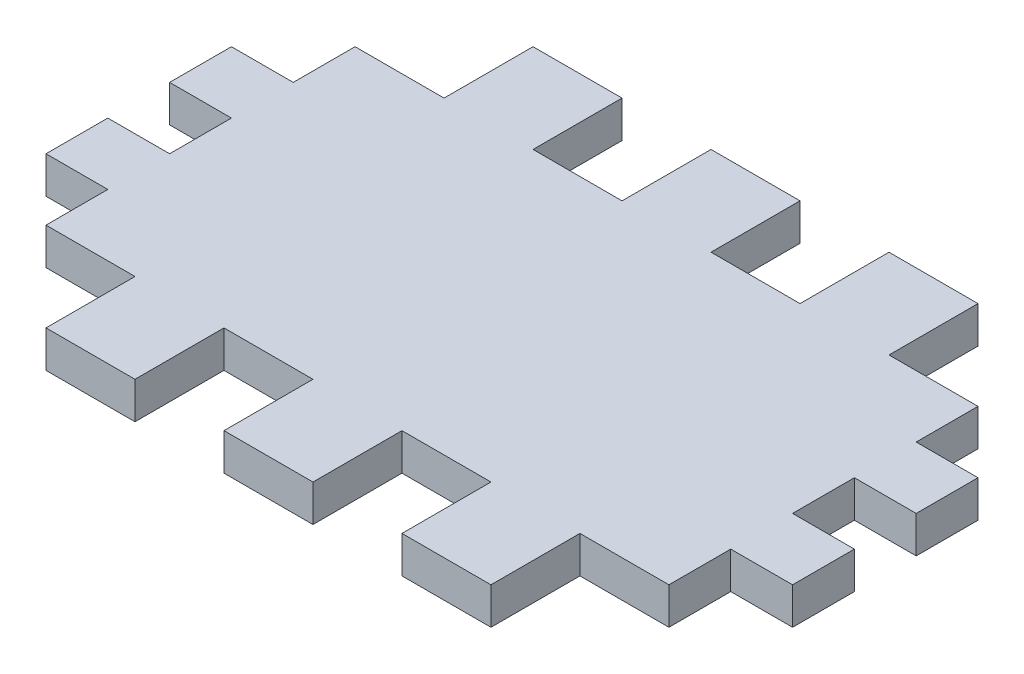
from build123d import *

# Parameters (mm, degrees)
BOSS_EXTRUDE1_DEPTH = 9.2


with BuildPart() as part:
    # Sketch3 → Boss-Extrude1 (new body)
    with BuildSketch(Plane(origin=(0, 0, 0), x_dir=(1, 0, 0), z_dir=(0, 1, 0))):
        Polygon((-273.026233767, 15.44), (-250.797662338, 15.44), (-250.797662338, 37.6685814), (-228.569090909, 37.6685814), (-228.569090909, 15.44), (-206.340519481, 15.44), (-206.340519481, 37.6685814), (-184.111948052, 37.6685814), (-184.111948052, 15.44), (-161.883376624, 15.44), (-161.883376624, 37.6685814), (-139.654805195, 37.6685814), (-139.654805195, 15.44), (-117.426233766, 15.44), (-117.426233766, 0), (-101.986233766, 0), (-101.986233766, -15.44), (-117.426233766, -15.44), (-117.426233766, -30.88), (-101.986233766, -30.88), (-101.986233766, -46.32), (-117.426233766, -46.32), (-117.426233766, -61.76), (-139.654805195, -61.76), (-139.654805195, -83.9885814), (-161.883376624, -83.9885814), (-161.883376624, -61.76), (-184.111948052, -61.76), (-184.111948052, -83.9885814), (-206.340519481, -83.9885814), (-206.340519481, -61.76), (-228.569090909, -61.76), (-228.569090909, -83.9885814), (-250.797662338, -83.9885814), (-250.797662338, -61.76), (-273.026233767, -61.76), (-273.026233767, -46.32), (-288.466233767, -46.32), (-288.466233767, -30.88), (-273.026233767, -30.88), (-273.026233767, -15.44), (-288.466233767, -15.44), (-288.466233767, 0), (-273.026233767, 0), align=None)
    extrude(amount=BOSS_EXTRUDE1_DEPTH)


solid = part.part
